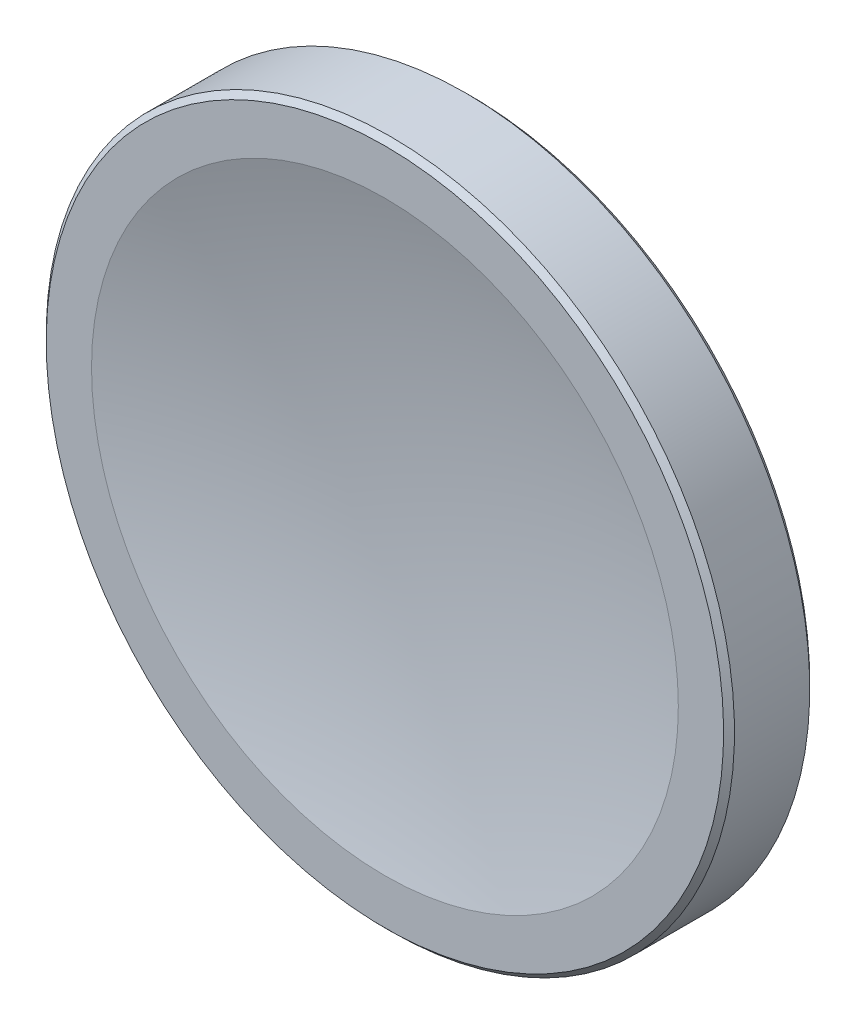
from build123d import *

# Parameters (mm, degrees)
CHAMFER1_SIZE = 1


with BuildPart() as part:
    # Sketch1 → Revolve3 (revolve)
    with BuildSketch(Plane(origin=(0, 0, 0), x_dir=(0, 0, -1), z_dir=(1, 0, 0))):
        with BuildLine():
            Line((-458.414283312, 54), (-458.414283312, 63.3349))
            Line((-458.414283312, 63.3349), (-442.555821638, 63.3349))
            Line((-442.555821638, 63.3349), (-442.555821638, 54))
            ThreePointArc((-442.555821638, 54), (-443.54515622, 27.008055426), (-443.875, 0))
            Line((-443.875, 0), (-451.375, 0))
            ThreePointArc((-451.375, 0), (-453.142234121, 27.228438761), (-458.414283312, 54))
        make_face()
    revolve(axis=Axis((0, 0, 662.018), (0, 0, -1)))

    # Chamfer1
    chamfer1_edges = [part.edges().sort_by_distance(p)[0] for p in [
        (0, -63.3349, 442.555821638),
        (0, -63.3349, 458.414283312),
    ]]
    chamfer(chamfer1_edges, length=CHAMFER1_SIZE)


solid = part.part
